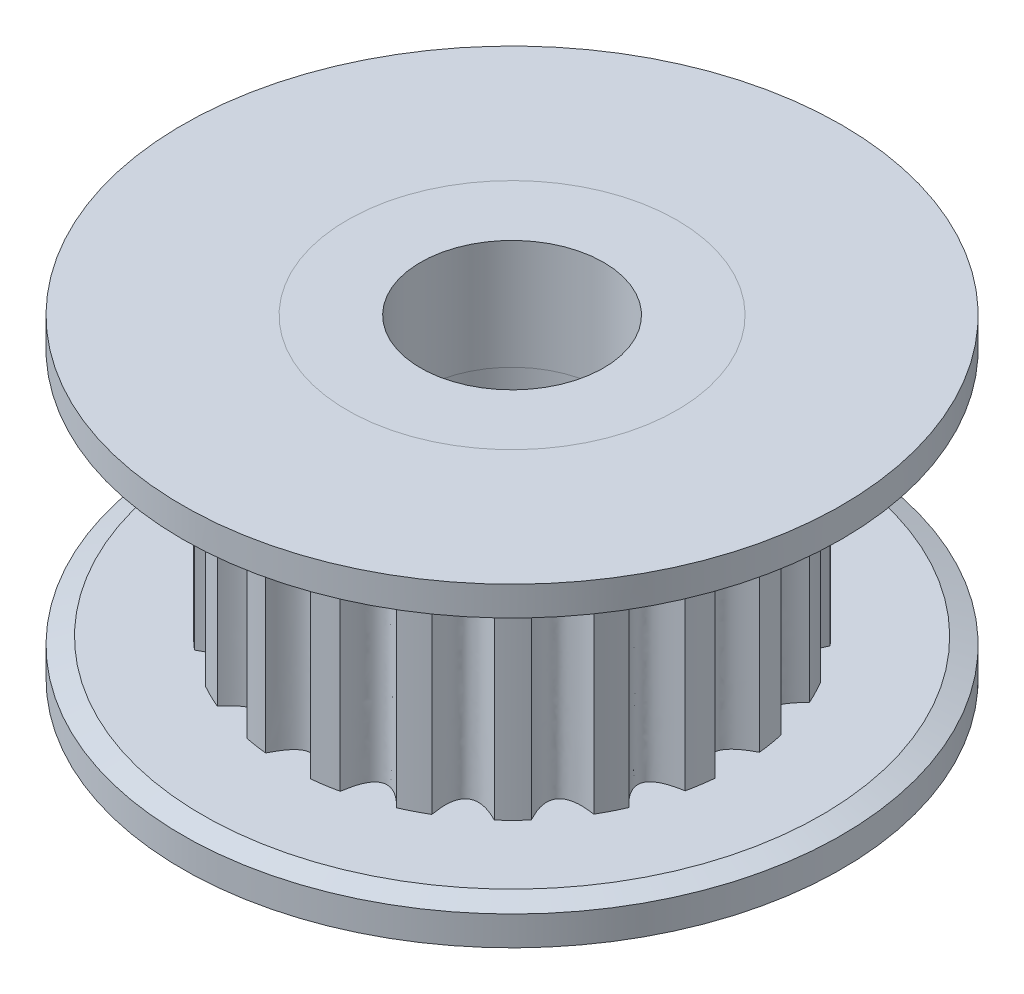
from build123d import *

# Parameters (mm, degrees)
CHANFRO1_SIZE         = 0.2
CHANFRO1_SIZE2        = 0.549495484
CHANFRO2_SIZE         = 0.2
CHANFRO2_SIZE2        = 0.549495484
ESBO_O2_W             = 2
ESBO_O2_H             = 3
CORTE_EXTRUS_O1_DEPTH = 6.6


with BuildPart() as part:
    # Esboço1 → Revolução1 (revolve)
    with BuildSketch(Plane.XY):
        Polygon((-4.5, 0), (-9, 0), (-9, 1), (-6.15, 1), (-6.15, 7.6), (-9, 7.6), (-9, 8.6), (-4.5, 8.6), (-4.5, 5.6), (-2.5, 5.6), (-2.5, 3), (-4.5, 3), align=None)
    revolve(axis=Axis((0, 0, 0), (0, 1, 0)))

    # Chanfro1
    chanfro1_edges = [part.edges().sort_by_distance(p)[0] for p in [
        (9, 1, 0),
    ]]
    chanfro1_side = [part.faces().sort_by_distance(p)[0] for p in [
        (9, 0.5, 0),
    ]]
    chamfer(chanfro1_edges, length=CHANFRO1_SIZE, length2=CHANFRO1_SIZE2, reference=chanfro1_side[0])

    # Chanfro2
    chanfro2_edges = [part.edges().sort_by_distance(p)[0] for p in [
        (9, 7.6, 0),
    ]]
    chanfro2_side = [part.faces().sort_by_distance(p)[0] for p in [
        (9, 8.1, 0),
    ]]
    chamfer(chanfro2_edges, length=CHANFRO2_SIZE, length2=CHANFRO2_SIZE2, reference=chanfro2_side[0])

    # Esboço3 → Corte-extrusão1 (cut)
    with BuildSketch(Plane.XZ.offset(-7.6)):
        with BuildLine():
            ThreePointArc((0.61126857, 6.119546612), (0, 6.15), (-0.61126857, 6.119546612))
            add(Edge.make_bspline(
                [(0.61126857, 6.119546612), (0, 4.880453388), (-0.61126857, 6.119546612)],
                knots=[0, 0, 0, 1, 1, 1], degree=2))
        make_face()
        with BuildLine():
            ThreePointArc((2.477563874, 5.62886998), (1.90582379, 5.847250267), (1.315209302, 6.007722072))
            add(Edge.make_bspline(
                [(2.477563874, 5.62886998), (1.507530289, 4.641762361), (1.315209302, 6.007722072)],
                knots=[0, 0, 0, 1, 1, 1], degree=2))
        make_face()
        with BuildLine():
            ThreePointArc((4.099930137, 4.58400184), (3.624009322, 4.968808351), (3.112197983, 5.304406066))
            add(Edge.make_bspline(
                [(4.099930137, 4.58400184), (2.867573845, 3.94904622), (3.112197983, 5.304406066)],
                knots=[0, 0, 0, 1, 1, 1], degree=2))
        make_face()
        with BuildLine():
            ThreePointArc((5.318636967, 3.087814892), (4.985392299, 3.601161427), (4.602774595, 4.078843712))
            add(Edge.make_bspline(
                [(5.318636967, 3.087814892), (3.947079313, 2.87008914), (4.602774595, 4.078843712)],
                knots=[0, 0, 0, 1, 1, 1], degree=2))
        make_face()
        with BuildLine():
            ThreePointArc((6.013696343, 1.287616518), (5.855937491, 1.878961442), (5.640184124, 2.451697994))
            add(Edge.make_bspline(
                [(6.013696343, 1.287616518), (4.640452509, 1.510466561), (5.640184124, 2.451697994)],
                knots=[0, 0, 0, 1, 1, 1], degree=2))
        make_face()
        with BuildLine():
            ThreePointArc((6.116676055, -0.639354395), (6.149935199, -0.028232064), (6.122288209, 0.583169864))
            add(Edge.make_bspline(
                [(6.116676055, -0.639354395), (4.879889539, 0.003209909), (6.122288209, 0.583169864)],
                knots=[0, 0, 0, 1, 1, 1], degree=2))
        make_face()
        with BuildLine():
            ThreePointArc((5.617437216, -2.503377544), (5.83843982, -1.932645976), (6.001621197, -1.34277437))
            add(Edge.make_bspline(
                [(5.617437216, -2.503377544), (4.642009607, -1.504215684), (6.001621197, -1.34277437)],
                knots=[0, 0, 0, 1, 1, 1], degree=2))
        make_face()
        with BuildLine():
            ThreePointArc((4.565132484, -4.120930162), (4.952119693, -3.646780847), (5.290063383, -3.136515488))
            add(Edge.make_bspline(
                [(4.565132484, -4.120930162), (3.950138384, -2.864345261), (5.290063383, -3.136515488)],
                knots=[0, 0, 0, 1, 1, 1], degree=2))
        make_face()
        with BuildLine():
            ThreePointArc((3.063366731, -5.332755786), (3.578237643, -5.001871187), (4.057671332, -4.621450353))
            add(Edge.make_bspline(
                [(3.063366731, -5.332755786), (2.872018914, -3.944146003), (4.057671332, -4.621450353)],
                knots=[0, 0, 0, 1, 1, 1], degree=2))
        make_face()
        with BuildLine():
            ThreePointArc((1.2599966, -6.019543884), (1.852059497, -5.86450131), (2.425780447, -5.651379409))
            add(Edge.make_bspline(
                [(1.2599966, -6.019543884), (1.513174901, -4.638034163), (2.425780447, -5.651379409)],
                knots=[0, 0, 0, 1, 1, 1], degree=2))
        make_face()
        with BuildLine():
            ThreePointArc((-0.667426746, -6.113676598), (-0.056463533, -6.149740797), (0.555058868, -6.124900787))
            add(Edge.make_bspline(
                [(-0.667426746, -6.113676598), (0.006576996, -4.878202716), (0.555058868, -6.124900787)],
                knots=[0, 0, 0, 1, 1, 1], degree=2))
        make_face()
        with BuildLine():
            ThreePointArc((-2.529138459, -5.605886072), (-1.959427435, -5.829506337), (-1.370311141, -5.995393847))
            add(Edge.make_bspline(
                [(-2.529138459, -5.605886072), (-1.500375367, -4.64124909), (-1.370311141, -5.995393847)],
                knots=[0, 0, 0, 1, 1, 1], degree=2))
        make_face()
        with BuildLine():
            ThreePointArc((-4.141843345, -4.546166925), (-3.669475521, -4.935326677), (-3.160766896, -5.275609219))
            add(Edge.make_bspline(
                [(-4.141843345, -4.546166925), (-2.860281353, -3.950454989), (-3.160766896, -5.275609219)],
                knots=[0, 0, 0, 1, 1, 1], degree=2))
        make_face()
        with BuildLine():
            ThreePointArc((-5.346762225, -3.038854013), (-5.018244668, -3.555238452), (-4.640028721, -4.036413442))
            add(Edge.make_bspline(
                [(-5.346762225, -3.038854013), (-3.940162474, -2.873496238), (-4.640028721, -4.036413442)],
                knots=[0, 0, 0, 1, 1, 1], degree=2))
        make_face()
        with BuildLine():
            ThreePointArc((-6.025264572, -1.232350129), (-5.872941544, -1.825118523), (-5.6624556, -2.399811781))
            add(Edge.make_bspline(
                [(-6.025264572, -1.232350129), (-4.634470584, -1.515808235), (-5.6624556, -2.399811781)],
                knots=[0, 0, 0, 1, 1, 1], degree=2))
        make_face()
        with BuildLine():
            ThreePointArc((-6.110548304, 0.695485032), (-6.149416798, 0.084693812), (-6.127384292, -0.526936176))
            add(Edge.make_bspline(
                [(-6.110548304, 0.695485032), (-4.875407146, -0.010257903), (-6.127384292, -0.526936176)],
                knots=[0, 0, 0, 1, 1, 1], degree=2))
        make_face()
        with BuildLine():
            ThreePointArc((-5.594216793, 2.554846076), (-5.820450005, 1.986167601), (-5.989040152, 1.397819035))
            add(Edge.make_bspline(
                [(-5.594216793, 2.554846076), (-4.63954452, 1.495865517), (-5.989040152, 1.397819035)],
                knots=[0, 0, 0, 1, 1, 1], degree=2))
        make_face()
        with BuildLine():
            ThreePointArc((-4.527105562, 4.162669244), (-4.918429655, 3.692092866), (-5.261043879, 3.184951695))
            add(Edge.make_bspline(
                [(-4.527105562, 4.162669244), (-3.950102511, 2.855266321), (-5.261043879, 3.184951695)],
                knots=[0, 0, 0, 1, 1, 1], degree=2))
        make_face()
        with BuildLine():
            ThreePointArc((-3.014277257, 5.360655988), (-3.53216434, 5.034512397), (-4.01507049, 4.658509307))
            add(Edge.make_bspline(
                [(-3.014277257, 5.360655988), (-2.874659117, 3.935053197), (-4.01507049, 4.658509307)],
                knots=[0, 0, 0, 1, 1, 1], degree=2))
        make_face()
        with BuildLine():
            ThreePointArc((-1.204677688, 6.030858286), (-1.798139087, 5.881258014), (-2.373792542, 5.673412462))
            add(Edge.make_bspline(
                [(-1.204677688, 6.030858286), (-1.518521518, 4.629734513), (-2.373792542, 5.673412462)],
                knots=[0, 0, 0, 1, 1, 1], degree=2))
        make_face()
    extrude(amount=CORTE_EXTRUS_O1_DEPTH, mode=Mode.SUBTRACT)


with BuildPart() as body_2:
    # Esboço2 → Revolução2 (revolve)
    with BuildSketch(Plane.XY):
        with Locations((-3.5, 1.5)):
            Rectangle(ESBO_O2_W, ESBO_O2_H)
        with Locations((-3.5, 7.1)):
            Rectangle(ESBO_O2_W, ESBO_O2_H)
    revolve(axis=Axis((0, 0, 0), (0, 1, 0)))


solid = Compound([part.part, body_2.part])
